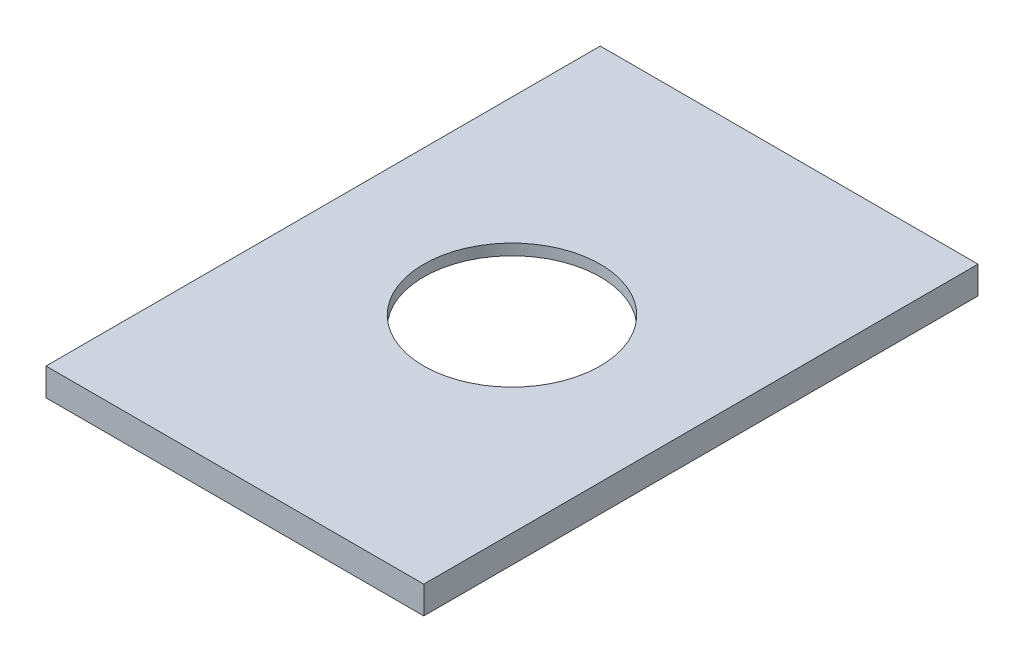
from build123d import *

# Parameters (mm, degrees)
CROQUIS1_W                   = 64.5
CROQUIS1_H                   = 96.5
CROQUIS1_R                   = 16
SALIENTE_EXTRUIR4_DEPTH      = 2
CROQUIS2_W                   = 68.5
CROQUIS2_H                   = 100.5
CROQUIS2_W_2                 = 64.5
CROQUIS2_H_2                 = 96.5
SALIENTE_EXTRUIR5_DEPTH      = 3
SALIENTE_EXTRUIR5_DEPTH_BACK = 2


with BuildPart() as part:
    # Croquis1 → Saliente-Extruir4 (new body)
    with BuildSketch(Plane(origin=(0, 0, 0), x_dir=(1, 0, 0), z_dir=(0, 1, 0))):
        with Locations((7.75, -11.25)):
            Rectangle(CROQUIS1_W, CROQUIS1_H)
        with Locations((7.75, -11.25)):
            Circle(CROQUIS1_R, mode=Mode.SUBTRACT)
    extrude(amount=SALIENTE_EXTRUIR4_DEPTH)

    # Croquis2 → Saliente-Extruir5 (add, two sides)
    with BuildSketch(Plane.XZ) as saliente_extruir5_sk:
        with Locations((7.75, 11.25)):
            Rectangle(CROQUIS2_W, CROQUIS2_H)
        with Locations((7.75, 11.25)):
            Rectangle(CROQUIS2_W_2, CROQUIS2_H_2, mode=Mode.SUBTRACT)
    extrude(amount=SALIENTE_EXTRUIR5_DEPTH)
    extrude(saliente_extruir5_sk.sketch, amount=-SALIENTE_EXTRUIR5_DEPTH_BACK)


solid = part.part
